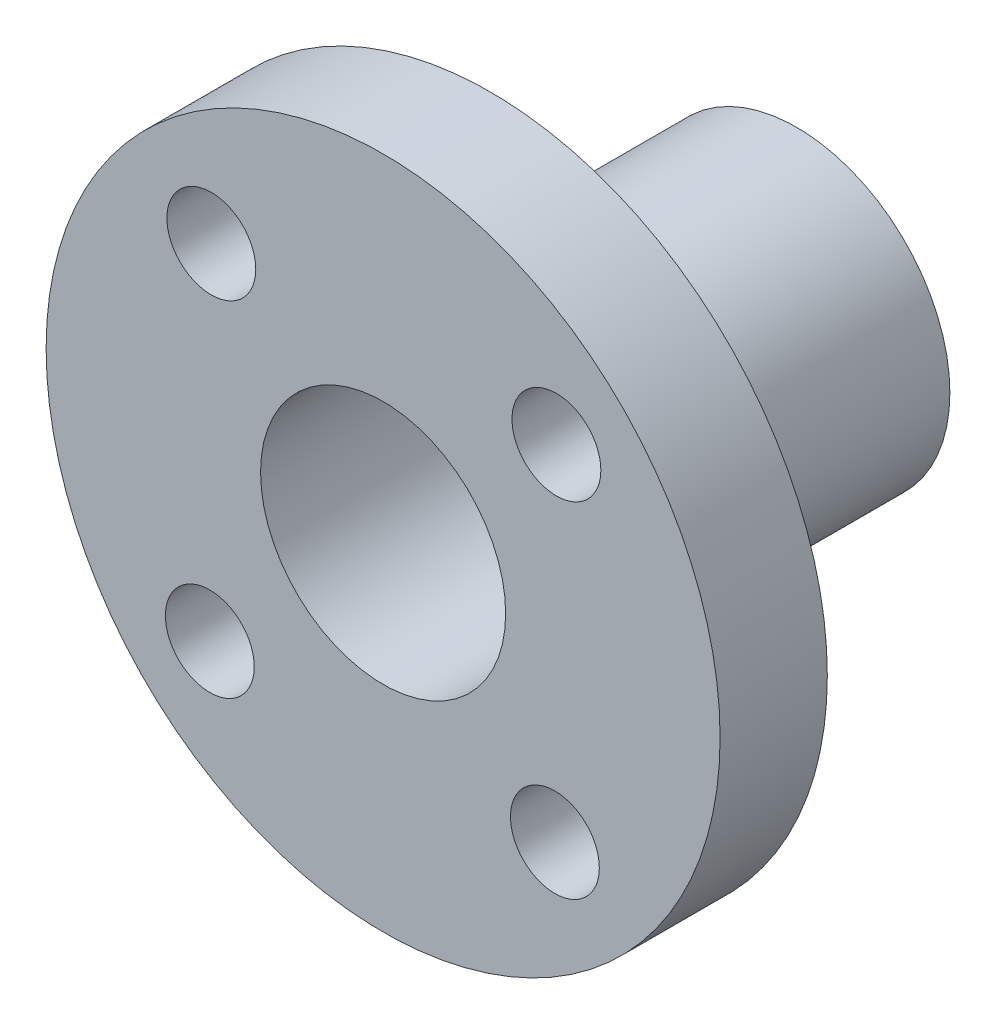
from build123d import *

# Parameters (mm, degrees)
SKETCH1_R           = 11
SKETCH1_R_2         = 4
SKETCH1_R_3         = 1.45
BOSS_EXTRUDE1_DEPTH = 3.5
SKETCH2_R           = 5
SKETCH2_R_2         = 4
BOSS_EXTRUDE2_DEPTH = 10


with BuildPart() as part:
    # Sketch1 → Boss-Extrude1 (new body)
    with BuildSketch(Plane.XY):
        with Locations((0.049999962, 219.95)):
            Circle(SKETCH1_R)
        with Locations((0.049999962, 219.95)):
            Circle(SKETCH1_R_2, mode=Mode.SUBTRACT)
        with Locations((5.656854228, 214.293145824)):
            Circle(SKETCH1_R_3, mode=Mode.SUBTRACT)
        with Locations((-5.606854214, 214.343145734)):
            Circle(SKETCH1_R_3, mode=Mode.SUBTRACT)
        with Locations((-5.556854304, 225.606854176)):
            Circle(SKETCH1_R_3, mode=Mode.SUBTRACT)
        with Locations((5.706854138, 225.556854266)):
            Circle(SKETCH1_R_3, mode=Mode.SUBTRACT)
    extrude(amount=BOSS_EXTRUDE1_DEPTH)

    # Sketch2 → Boss-Extrude2 (add)
    with BuildSketch(Plane(origin=(0, 0, 0), x_dir=(-1, 0, 0), z_dir=(0, 0, -1))):
        with Locations((-0.049999962, 219.95)):
            Circle(SKETCH2_R)
        with Locations((-0.049999962, 219.95)):
            Circle(SKETCH2_R_2, mode=Mode.SUBTRACT)
    extrude(amount=BOSS_EXTRUDE2_DEPTH)


solid = part.part
